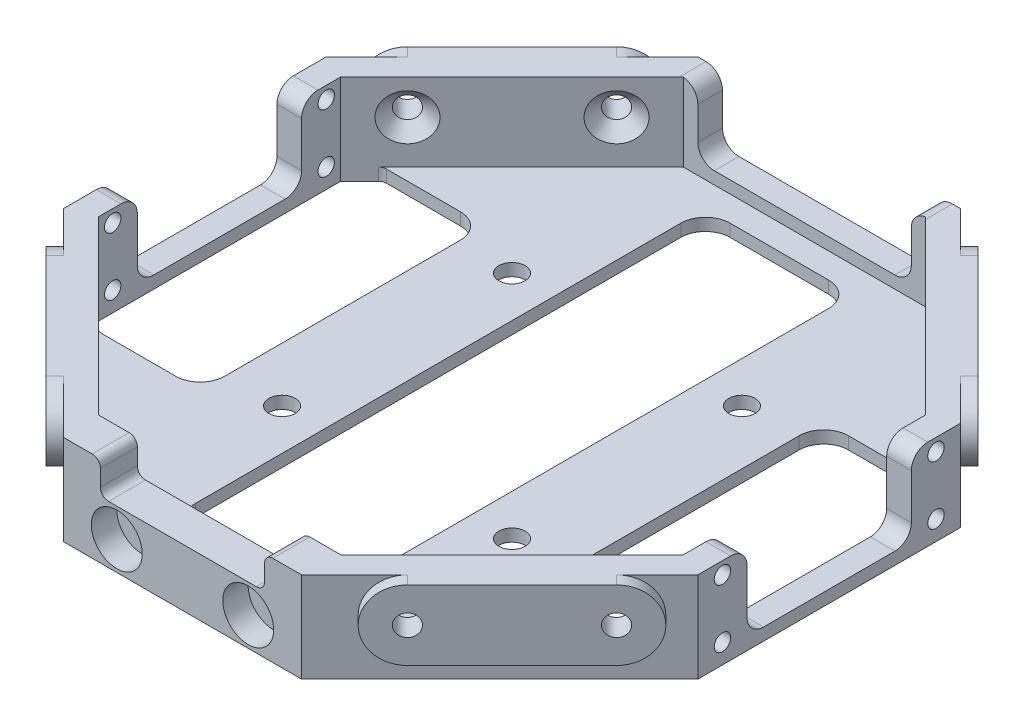
from build123d import *

# Parameters (mm, degrees)
BOSS_EXTRUDE1_DEPTH                        = 11
SHELL1_T                                   = -3
SHELL1_THICKNESS_2_DEPTH                   = 1.5
SKETCH2_R                                  = 1.3
CUT_EXTRUDE1_DEPTH                         = 152
SKETCH3_R                                  = 1.3
CUT_EXTRUDE2_DEPTH                         = 152
CUT_EXTRUDE3_DEPTH                         = 152
SKETCH5_W                                  = 13
SKETCH5_H                                  = 8
CUT_EXTRUDE4_DEPTH                         = 45
FILLET1_R                                  = 2
CUT_EXTRUDE6_DEPTH                         = 92
SKETCH6_R                                  = 1
CUT_EXTRUDE7_DEPTH                         = 5
SKETCH12_R                                 = 1
CUT_EXTRUDE8_DEPTH                         = 5
FILLET2_R                                  = 1
BOSS_EXTRUDE2_DEPTH                        = 11
SKETCH14_R                                 = 3.1
CUT_EXTRUDE9_DEPTH                         = 3.1
CUT_EXTRUDE10_DEPTH                        = 9.1
FILLET3_R                                  = 1
SKETCH19_R                                 = 1.6
CUT_EXTRUDE12_DEPTH                        = 10
FILLET4_R                                  = 3
CHAMFER1_SIZE                              = 1.5
BOSS_EXTRUDE3_START                        = 1.5
SKETCH20_R                                 = 1.3
BOSS_EXTRUDE3_DEPTH                        = 1.5
MIRROR1_START                              = 1.5
MIRROR1_AT_THE_SECOND_PLANE_COPY_1_SKETC_R = 1.3
MIRROR1_AT_THE_SECOND_PLANE_COPY_1_DEPTH   = 1.5


with BuildPart() as part:
    # Sketch1 → Boss-Extrude1 (new body)
    with BuildSketch(Plane(origin=(0, 0, 0), x_dir=(1, 0, 0), z_dir=(0, 1, 0))):
        Polygon((38.627416998, 16), (16, 38.627416998), (-16, 38.627416998), (-38.627416998, 16), (-38.627416998, -16), (-16, -38.627416998), (16, -38.627416998), (38.627416998, -16), align=None)
    extrude(amount=BOSS_EXTRUDE1_DEPTH)

    # Shell1
    shell1_openings = [part.faces().sort_by_distance(p)[0] for p in [
        (0, 11, 0),
    ]]
    offset(amount=SHELL1_T, openings=shell1_openings, kind=Kind.INTERSECTION)

    # Shell1 thickness 2 face (on inner face of the shell) → Shell1 thickness 2 (cut)
    with BuildSketch(Plane(origin=(0, 3, 0), x_dir=(0, 0, -1), z_dir=(0, -1, 0))):
        Polygon((-14.757359313, 35.627416998), (14.757359313, 35.627416998), (35.627416998, 14.757359313), (35.627416998, -14.757359313), (14.757359313, -35.627416998), (-14.757359313, -35.627416998), (-35.627416998, -14.757359313), (-35.627416998, 14.757359313), align=None)
    extrude(amount=SHELL1_THICKNESS_2_DEPTH, mode=Mode.SUBTRACT)

    # Sketch2 → Cut-Extrude1 (cut)
    with BuildSketch(Plane(origin=(27.313708499, 0, 27.313708499), x_dir=(0.7071067811865475, 0, -0.7071067811865477), z_dir=(0.7071067811865477, 0, 0.7071067811865475))):
        with Locations((9, 6.75)):
            Circle(SKETCH2_R)
        with Locations((-9, 6.75)):
            Circle(SKETCH2_R)
    extrude(amount=-CUT_EXTRUDE1_DEPTH, mode=Mode.SUBTRACT)

    # Sketch3 → Cut-Extrude2 (cut)
    with BuildSketch(Plane(origin=(-27.313708499, 0, 27.313708499), x_dir=(0.7071067811865476, 0, 0.7071067811865476), z_dir=(-0.7071067811865476, 0, 0.7071067811865476))):
        with Locations((9, 6.75)):
            Circle(SKETCH3_R)
        with Locations((-9, 6.75)):
            Circle(SKETCH3_R)
    extrude(amount=-CUT_EXTRUDE2_DEPTH, mode=Mode.SUBTRACT)

    # Sketch4 → Cut-Extrude3 (cut)
    with BuildSketch(Plane(origin=(38.627416998, 0, 0), x_dir=(0, 0, -1), z_dir=(1, 0, 0))):
        Polygon((0, 1.5), (10, 1.5), (10, 11), (0, 11), (-10, 11), (-10, 1.5), align=None)
    extrude(amount=-CUT_EXTRUDE3_DEPTH, mode=Mode.SUBTRACT)

    # Sketch5 → Cut-Extrude4 (cut)
    with BuildSketch(Plane(origin=(0, 0, -38.627416998), x_dir=(-1, 0, 0), z_dir=(0, 0, -1))):
        with Locations((-6.5, 7)):
            Rectangle(SKETCH5_W, SKETCH5_H)
        with Locations((6.5, 7)):
            Rectangle(SKETCH5_W, SKETCH5_H)
    extrude(amount=-CUT_EXTRUDE4_DEPTH, mode=Mode.SUBTRACT)

    # Fillet1
    fillet1_edges = [part.edges().sort_by_distance(p)[0] for p in [
        (-13, 11, -37.127416998),
        (-13, 3, -37.127416998),
        (13, 11, -37.127416998),
        (13, 3, -37.127416998),
        (37.127416998, 11, 10),
        (37.127416998, 1.5, 10),
        (37.127416998, 11, -10),
        (37.127416998, 1.5, -10),
        (-37.127416998, 11, -10),
        (-37.127416998, 1.5, -10),
        (-37.127416998, 11, 10),
        (-37.127416998, 1.5, 10),
    ]]
    fillet(fillet1_edges, radius=FILLET1_R)

    # Sketch7 → Cut-Extrude6 (cut)
    with BuildSketch(Plane(origin=(0, 1.5, 0), x_dir=(1, 0, 0), z_dir=(0, 1, 0))):
        Polygon((35.627416998, -10.000000003), (31.627416998, -10.000000003), (31.627416998, -18.757359313), (35.627416998, -14.757359313), align=None)
        Polygon((35.627416998, 14.757359313), (35.627416998, 10.000000003), (31.627416998, 10.000000003), (31.627416998, 18.757359313), align=None)
        Polygon((-35.627416998, 10.000000003), (-31.627416998, 10.000000003), (-31.627416998, 18.757359313), (-35.627416998, 14.757359313), align=None)
        Polygon((-35.627416998, -14.757359313), (-35.627416998, -10.000000003), (-31.627416998, -10.000000003), (-31.627416998, -18.757359313), align=None)
    extrude(amount=-CUT_EXTRUDE6_DEPTH, mode=Mode.SUBTRACT)

    # Sketch6 → Cut-Extrude7 (cut)
    with BuildSketch(Plane(origin=(38.627416998, 0, 0), x_dir=(0, 0, -1), z_dir=(1, 0, 0))):
        with Locations((-13, 9.5)):
            Circle(SKETCH6_R)
        with Locations((-13, 2.4)):
            Circle(SKETCH6_R)
        with Locations((13, 2.4)):
            Circle(SKETCH6_R)
        with Locations((13, 9.5)):
            Circle(SKETCH6_R)
    extrude(amount=-CUT_EXTRUDE7_DEPTH, mode=Mode.SUBTRACT)

    # Sketch12 → Cut-Extrude8 (cut)
    with BuildSketch(Plane(origin=(-35.627416998, 0, 0), x_dir=(0, 0, -1), z_dir=(1, 0, 0))):
        with Locations((-13, 9.5)):
            Circle(SKETCH12_R)
        with Locations((-13, 2.4)):
            Circle(SKETCH12_R)
        with Locations((13, 2.4)):
            Circle(SKETCH12_R)
        with Locations((13, 9.5)):
            Circle(SKETCH12_R)
    extrude(amount=-CUT_EXTRUDE8_DEPTH, mode=Mode.SUBTRACT)

    # Fillet2
    fillet2_edges = [part.edges().sort_by_distance(p)[0] for p in [
        (-31.627416998, 0.75, 10.000000003),
        (-31.627416998, 0.75, 18.757359313),
        (-35.627416998, 0.75, 10.000000003),
        (35.627416998, 0.75, -10.000000003),
        (31.627416998, 0.75, -10.000000003),
        (31.627416998, 0.75, -18.757359313),
        (31.627416998, 0.75, 10.000000003),
        (35.627416998, 0.75, 10.000000003),
        (31.627416998, 0.75, 18.757359313),
        (-31.627416998, 0.75, -10.000000003),
        (-35.627416998, 0.75, -10.000000003),
        (-31.627416998, 0.75, -18.757359313),
    ]]
    fillet(fillet2_edges, radius=FILLET2_R)

    # Sketch13 → Boss-Extrude2 (add)
    with BuildSketch(Plane(origin=(0, 11, 0), x_dir=(1, 0, 0), z_dir=(0, 1, 0))):
        Polygon((0, -38.627416998), (-16, -38.627416998), (-14.5, -40.127416998), (0, -40.127416998), align=None)
        Polygon((16, -38.627416998), (0, -38.627416998), (0, -40.127416998), (14.5, -40.127416998), align=None)
    extrude(amount=-BOSS_EXTRUDE2_DEPTH)

    # Sketch14 → Cut-Extrude9 (cut)
    with BuildSketch(Plane.XY.offset(40.127416998)):
        with Locations((8, 3.5)):
            Circle(SKETCH14_R)
        with Locations((-8, 3.5)):
            Circle(SKETCH14_R)
    extrude(amount=-CUT_EXTRUDE9_DEPTH, mode=Mode.SUBTRACT)

    # Sketch18 → Cut-Extrude10 (cut)
    with BuildSketch(Plane.XY.offset(40.127416998)):
        Polygon((-10, 7), (0, 7), (10, 7), (10, 11), (-10, 11), align=None)
    extrude(amount=-CUT_EXTRUDE10_DEPTH, mode=Mode.SUBTRACT)

    # Fillet3
    fillet3_edges = [part.edges().sort_by_distance(p)[0] for p in [
        (-10, 7, 37.877416998),
        (-10, 11, 37.877416998),
        (10, 11, 37.877416998),
        (10, 7, 37.877416998),
    ]]
    fillet(fillet3_edges, radius=FILLET3_R)

    # Sketch19 → Cut-Extrude12 (cut)
    with BuildSketch(Plane(origin=(0, 0, 0), x_dir=(-1, 0, 0), z_dir=(0, -1, 0))):
        Polygon((9, -32.556349186), (9, 32.556349186), (-9, 32.556349186), (-9, -14), (-9, -32.556349186), align=None)
        with Locations(Location((-14, -14, 0), (0, 0, 90))):
            Circle(SKETCH19_R)
        Polygon((-20.627416998, -17.343145751), (-20.627416998, 17.343145751), (-32.627416998, 17.343145751), (-32.627416998, 11.000000003), (-35.627416998, 11.000000003), (-35.627416998, -11.000000003), (-32.627416998, -11), (-32.627416998, -17.343145751), align=None)
        Polygon((35.627416998, -11.000000003), (35.627416998, 11.000000003), (32.627416998, 11.000000003), (32.627416998, 17.343145751), (20.627416998, 17.343145751), (20.627416998, -17.343145751), (32.627416998, -17.343145751), (32.627416998, -11), align=None)
        with Locations(Location((14, -14, 0), (0, 0, 90))):
            Circle(SKETCH19_R)
        with Locations(Location((-14, 14, 0), (0, 0, 90))):
            Circle(SKETCH19_R)
        with Locations(Location((14, 14, 0), (0, 0, 90))):
            Circle(SKETCH19_R)
    extrude(amount=-CUT_EXTRUDE12_DEPTH, mode=Mode.SUBTRACT)

    # Fillet4
    fillet4_edges = [part.edges().sort_by_distance(p)[0] for p in [
        (-20.627416998, 0.75, 17.343145751),
        (-20.627416998, 0.75, -17.343145751),
        (20.627416998, 0.75, -17.343145751),
        (20.627416998, 0.75, 17.343145751),
        (-9, 0.75, 32.556349186),
        (9, 0.75, 32.556349186),
        (9, 0.75, -32.556349186),
        (-9, 0.75, -32.556349186),
    ]]
    fillet(fillet4_edges, radius=FILLET4_R)

    # Chamfer1
    chamfer1_edges = [part.edges().sort_by_distance(p)[0] for p in [
        (17.909188309, 6.75, 32.475588002),
        (-32.475588002, 6.75, -17.909188309),
        (30.637110371, 6.75, 19.74766594),
        (-19.74766594, 6.75, -30.637110371),
        (-19.74766594, 6.75, 30.637110371),
        (30.637110371, 6.75, -19.74766594),
        (-32.475588002, 6.75, 17.909188309),
        (17.909188309, 6.75, -32.475588002),
    ]]
    chamfer(chamfer1_edges, length=CHAMFER1_SIZE)

    # Sketch20 → Boss-Extrude3 (add)
    with BuildSketch(Plane(origin=(27.313708499, 0, 27.313708499), x_dir=(0.7071067811865475, 0, -0.7071067811865477), z_dir=(0.7071067811865477, 0, 0.7071067811865475)).offset(BOSS_EXTRUDE3_START)):
        with BuildLine():
            Line((-9, 2.5), (9, 2.5))
            ThreePointArc((9, 2.5), (13.25, 6.75), (9, 11))
            Line((9, 11), (-9, 11))
            ThreePointArc((-9, 11), (-13.25, 6.75), (-9, 2.5))
        make_face()
        with Locations((-9, 6.75)):
            Circle(SKETCH20_R, mode=Mode.SUBTRACT)
        with Locations((9, 6.75)):
            Circle(SKETCH20_R, mode=Mode.SUBTRACT)
    boss_extrude3 = extrude(amount=-BOSS_EXTRUDE3_DEPTH)

    # Mirror1: Boss-Extrude3 across plane
    add(boss_extrude3.mirror(Plane(origin=(0, 0, 0), x_dir=(0, 0, 1), z_dir=(1, 0, 0))))

    # Mirror1 at the second plane: Boss-Extrude3 across plane
    add(boss_extrude3.mirror(Plane.XY))

    # Mirror1 at the second plane copy 1 sketc → Mirror1 at the second plane copy 1 (add)
    with BuildSketch(Plane(origin=(-27.313708499, 0, -27.313708499), x_dir=(-0.7071067811865475, 0, 0.7071067811865477), z_dir=(-0.7071067811865477, 0, -0.7071067811865475)).offset(MIRROR1_START)):
        with BuildLine():
            Line((-9, 2.5), (9, 2.5))
            ThreePointArc((9, 2.5), (13.25, 6.75), (9, 11))
            Line((9, 11), (-9, 11))
            ThreePointArc((-9, 11), (-13.25, 6.75), (-9, 2.5))
        make_face()
        with Locations((-9, 6.75)):
            Circle(MIRROR1_AT_THE_SECOND_PLANE_COPY_1_SKETC_R, mode=Mode.SUBTRACT)
        with Locations((9, 6.75)):
            Circle(MIRROR1_AT_THE_SECOND_PLANE_COPY_1_SKETC_R, mode=Mode.SUBTRACT)
    extrude(amount=-MIRROR1_AT_THE_SECOND_PLANE_COPY_1_DEPTH)


solid = part.part
